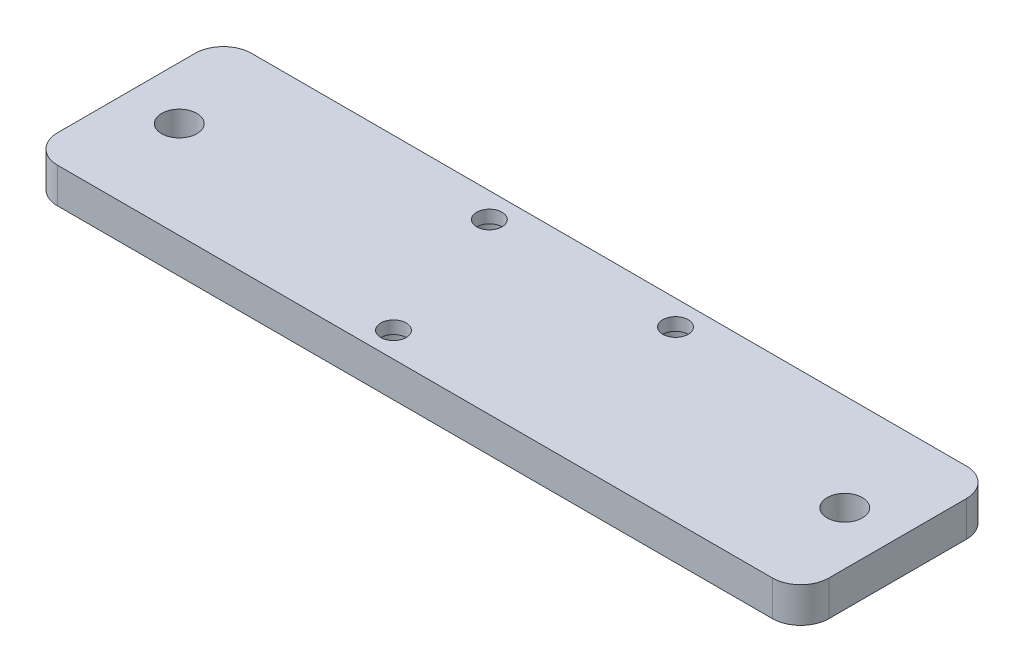
from build123d import *

# Parameters (mm, degrees)
SKETCH1_W           = 138.907683808
SKETCH1_H           = 34.925
SKETCH1_R           = 2.286
SKETCH1_R_2         = 3.175
BOSS_EXTRUDE1_DEPTH = 6.35
SKETCH2_R           = 3.556
CUT_EXTRUDE1_DEPTH  = 4.064
FILLET1_R           = 5.08


with BuildPart() as part:
    # Sketch1 → Boss-Extrude1 (new body)
    with BuildSketch(Plane(origin=(0, 0, 0), x_dir=(1, 0, 0), z_dir=(0, 1, 0))):
        with Locations((0.269158096, -12.954)):
            Rectangle(SKETCH1_W, SKETCH1_H)
        with Locations((16.764, 0)):
            Circle(SKETCH1_R, mode=Mode.SUBTRACT)
        with Locations((-16.764, 0)):
            Circle(SKETCH1_R, mode=Mode.SUBTRACT)
        with Locations((-8.128, -25.908)):
            Circle(SKETCH1_R, mode=Mode.SUBTRACT)
        with Locations((60.198, -12.954)):
            Circle(SKETCH1_R_2, mode=Mode.SUBTRACT)
        with Locations((-59.659683808, -12.954)):
            Circle(SKETCH1_R_2, mode=Mode.SUBTRACT)
    extrude(amount=BOSS_EXTRUDE1_DEPTH)

    # Sketch2 → Cut-Extrude1 (cut)
    with BuildSketch(Plane.XZ):
        with Locations((-8.128, 25.908)):
            Circle(SKETCH2_R)
        with Locations((-16.764, 0)):
            Circle(SKETCH2_R)
        with Locations((16.764, 0)):
            Circle(SKETCH2_R)
    extrude(amount=-CUT_EXTRUDE1_DEPTH, mode=Mode.SUBTRACT)

    # Fillet1
    fillet1_edges = [part.edges().sort_by_distance(p)[0] for p in [
        (69.723, 3.175, -4.5085),
        (69.723, 3.175, 30.4165),
        (-69.184683808, 3.175, -4.5085),
        (-69.184683808, 3.175, 30.4165),
    ]]
    fillet(fillet1_edges, radius=FILLET1_R)


solid = part.part
